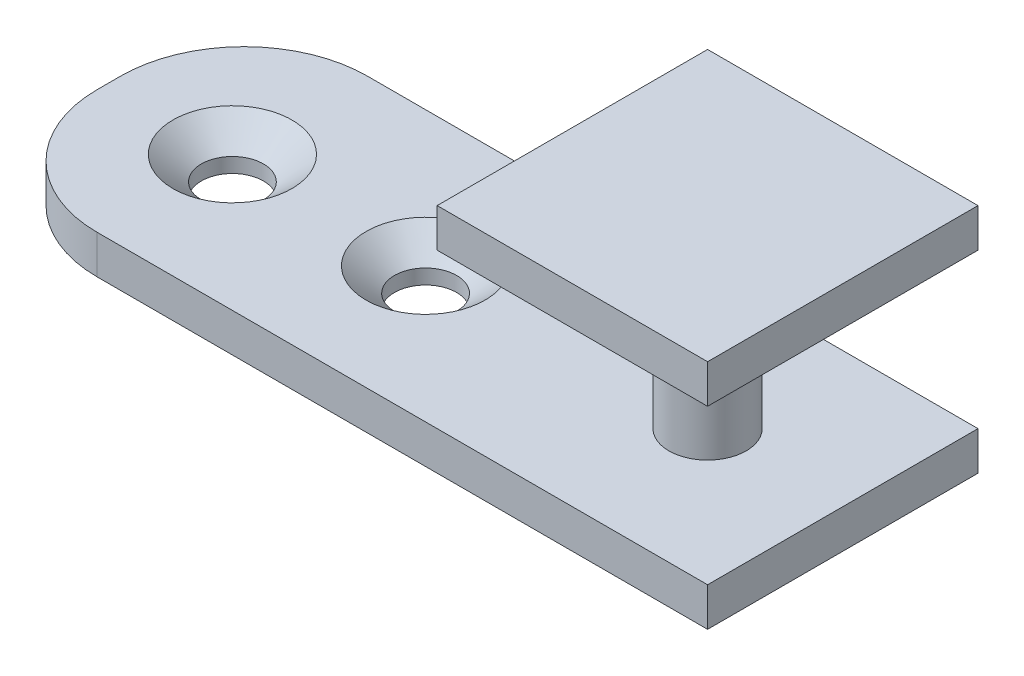
from build123d import *

# Parameters (mm, degrees)
SKETCH1_R                                  = 3.175
BOSS_EXTRUDE1_DEPTH                        = 12.7
SKETCH2_W                                  = 22.225
SKETCH2_H                                  = 22.225
BOSS_EXTRUDE2_DEPTH                        = 3.175
BOSS_EXTRUDE3_DEPTH                        = 3.175
CSK_FOR_10_FLAT_HEAD_MACHINE_SCREW_2_COUNT = 2
CSK_FOR_10_FLAT_HEAD_MACHINE_SCREW_2_PITCH = 15.875


with BuildPart() as part:
    # Sketch1 → Boss-Extrude1 (new body)
    with BuildSketch(Plane(origin=(0, 0, 0), x_dir=(1, 0, 0), z_dir=(0, 1, 0))):
        Circle(SKETCH1_R)
    extrude(amount=BOSS_EXTRUDE1_DEPTH)

    # Sketch2 → Boss-Extrude2 (add)
    with BuildSketch(Plane(origin=(0, 12.7, 0), x_dir=(1, 0, 0), z_dir=(0, 1, 0))):
        Rectangle(SKETCH2_W, SKETCH2_H)
    boss_extrude2 = extrude(amount=BOSS_EXTRUDE2_DEPTH)

    # Mirror1: Boss-Extrude2 across plane
    add(boss_extrude2.mirror(Plane(origin=(0, 6.35, 0), x_dir=(0, 0, 1), z_dir=(0, -1, 0))))

    # Sketch3 → Boss-Extrude3 (add)
    with BuildSketch(Plane.XZ.offset(3.175)):
        with BuildLine():
            Line((-11.1125, -11.1125), (-39.0525, -11.1125))
            ThreePointArc((-39.0525, -11.1125), (-46.236704897, -8.136704897), (-49.2125, -0.9525))
            Line((-49.2125, -0.9525), (-49.2125, 0.9525))
            ThreePointArc((-49.2125, 0.9525), (-46.236704897, 8.136704897), (-39.0525, 11.1125))
            Line((-39.0525, 11.1125), (-11.1125, 11.1125))
            Line((-11.1125, 11.1125), (-11.1125, -11.1125))
        make_face()
    extrude(amount=-BOSS_EXTRUDE3_DEPTH)

    # Sketch6 → CSK for _10 Flat Head Machine Screw _100 (revolve, cut)
    with BuildSketch(Plane(origin=(-39.0525, 0, 0), x_dir=(0, 0, 1), z_dir=(1, 0, 0))):
        Polygon((0, 0), (0, 3.175), (2.5527, 3.175), (2.5527, 1.960808018), (4.8895, 0), align=None)
    csk_for_10_flat_head_machine_screw_100 = revolve(axis=Axis((-39.0525, 6.35, 0), (0, -1, 0)), mode=Mode.SUBTRACT)

    # CSK for _10 Flat Head Machine Screw  2: CSK for _10 Flat Head Machine Screw _100 ×2
    with Locations(*[(i * CSK_FOR_10_FLAT_HEAD_MACHINE_SCREW_2_PITCH, 0, 0) for i in range(1, CSK_FOR_10_FLAT_HEAD_MACHINE_SCREW_2_COUNT)]):
        add(csk_for_10_flat_head_machine_screw_100, mode=Mode.SUBTRACT)


solid = part.part
